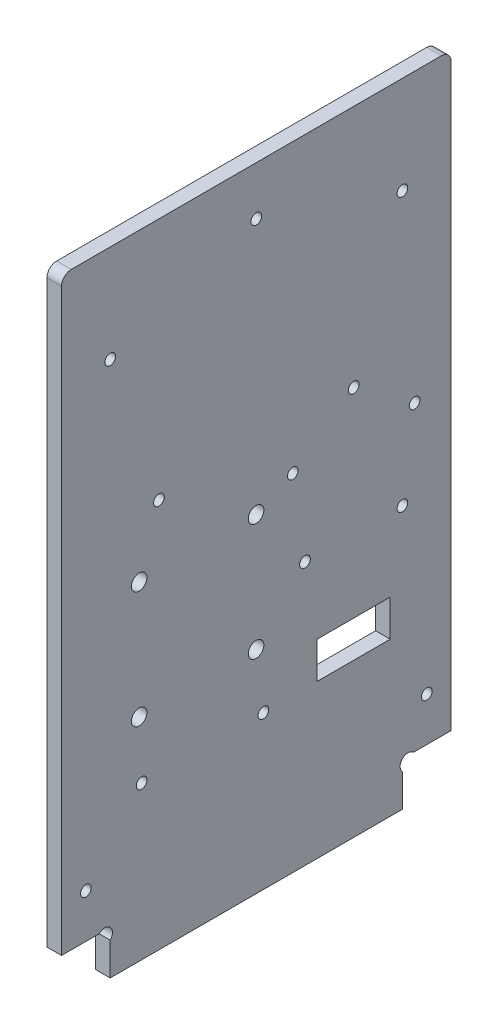
from build123d import *

# Parameters (mm, degrees)
EXTRUSION1_DEPTH        = 3
ESQUISSE2_R             = 1.1
ESQUISSE2_R_2           = 1.6
ENL_V_MAT_EXTRU_1_DEPTH = 4
ESQUISSE3_W             = 15
ESQUISSE3_H             = 7.5
ENL_V_MAT_EXTRU_2_DEPTH = 4
ESQUISSE4_R             = 1.1
ENL_V_MAT_EXTRU_3_DEPTH = 4
CONG_1_R                = 2
ESQUISSE5_R             = 1.1
ENL_V_MAT_EXTRU_6_DEPTH = 4


with BuildPart() as part:
    # Esquisse1 → Extrusion1 (new body)
    with BuildSketch(Plane(origin=(0, 0, 0), x_dir=(0, 0, -1), z_dir=(1, 0, 0))):
        with BuildLine():
            Line((10, 6.7372583), (10, 0))
            Line((10, 0), (70, 0))
            Line((70, 0), (70, 6.7372583))
            ThreePointArc((70, 6.7372583), (70, 9), (72.2627417, 9))
            Line((72.2627417, 9), (80, 9))
            Line((80, 9), (80, 130))
            Line((80, 130), (0, 130))
            Line((0, 130), (0, 9))
            Line((0, 9), (7.7372583, 9))
            ThreePointArc((7.7372583, 9), (10, 9), (10, 6.7372583))
        make_face()
    extrude(amount=EXTRUSION1_DEPTH)

    # Esquisse2 → Enlèv. mat.-Extru.1 (cut, through all)
    with BuildSketch(Plane(origin=(3, 0, 0), x_dir=(0, 0, -1), z_dir=(1, 0, 0))):
        with Locations((60, 80)):
            Circle(ESQUISSE2_R)
        with Locations((10, 110)):
            Circle(ESQUISSE2_R)
        with Locations(Location((20, 80, 0), (0, 0, 180))):  # turned: the seam where the file's is
            Circle(ESQUISSE2_R)
        with Locations((70, 110)):
            Circle(ESQUISSE2_R)
        with Locations((15.95, 67.45)):
            Circle(ESQUISSE2_R_2)
        with Locations((15.95, 43.45)):
            Circle(ESQUISSE2_R_2)
        with Locations((39.95, 43.45)):
            Circle(ESQUISSE2_R_2)
        with Locations((39.95, 67.45)):
            Circle(ESQUISSE2_R_2)
        with Locations((40, 120)):
            Circle(ESQUISSE2_R)
        with Locations((70, 54)):
            Circle(ESQUISSE2_R)
        with Locations((50, 54)):
            Circle(ESQUISSE2_R)
    extrude(amount=-ENL_V_MAT_EXTRU_1_DEPTH, mode=Mode.SUBTRACT)

    # Esquisse3 → Enlèv. mat.-Extru.2 (cut, through all)
    with BuildSketch(Plane.ZY):
        with Locations((-60, 35.25)):
            Rectangle(ESQUISSE3_W, ESQUISSE3_H)
    extrude(amount=-ENL_V_MAT_EXTRU_2_DEPTH, mode=Mode.SUBTRACT)

    # Esquisse4 → Enlèv. mat.-Extru.3 (cut, through all)
    with BuildSketch(Plane(origin=(3, 0, 0), x_dir=(0, 0, -1), z_dir=(1, 0, 0))):
        with Locations((75, 18)):
            Circle(ESQUISSE4_R)
        with Locations((5, 18)):
            Circle(ESQUISSE4_R)
    extrude(amount=-ENL_V_MAT_EXTRU_3_DEPTH, mode=Mode.SUBTRACT)

    # Congé1
    cong_1_edges = [part.edges().sort_by_distance(p)[0] for p in [
        (1.5, 130, 0),
        (1.5, 130, -80),
    ]]
    fillet(cong_1_edges, radius=CONG_1_R)

    # Esquisse5 → Enlèv. mat.-Extru.6 (cut, through all)
    with BuildSketch(Plane(origin=(3, 0, 0), x_dir=(0, 0, -1), z_dir=(1, 0, 0))):
        with Locations((16.45, 31.45)):
            Circle(ESQUISSE5_R)
        with Locations((41.45, 31.45)):
            Circle(ESQUISSE5_R)
        with Locations((47.5, 71)):
            Circle(ESQUISSE5_R)
        with Locations((72.5, 71)):
            Circle(ESQUISSE5_R)
    extrude(amount=-ENL_V_MAT_EXTRU_6_DEPTH, mode=Mode.SUBTRACT)


solid = part.part
